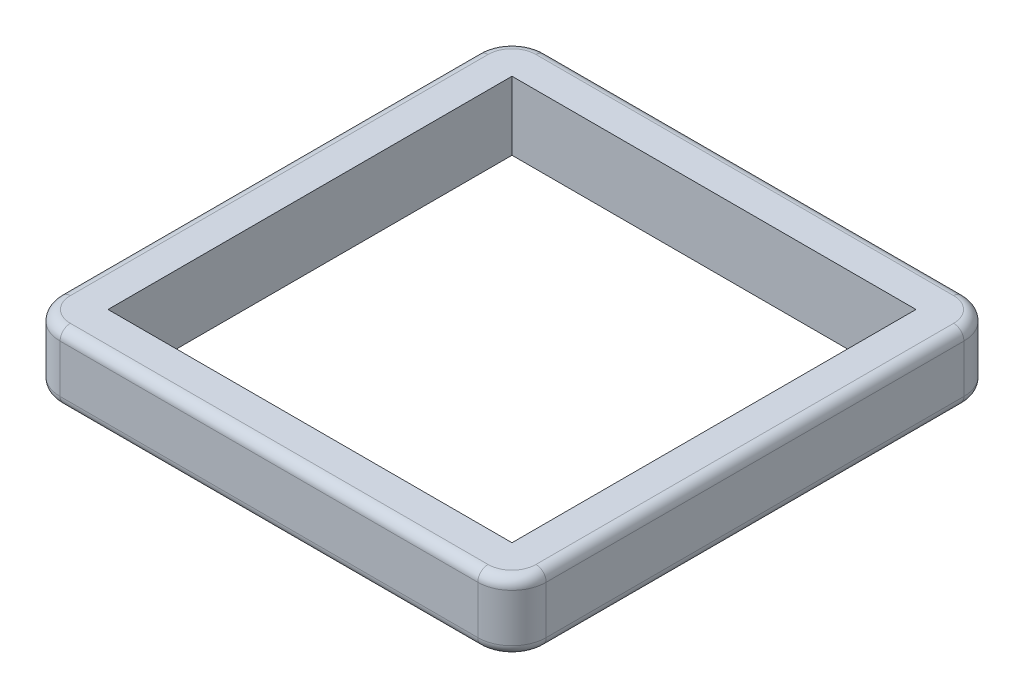
from build123d import *

# Parameters (mm, degrees)
SKETCH1_W           = 901.7
SKETCH1_H           = 901.7
SKETCH1_W_2         = 749.3
SKETCH1_H_2         = 749.3
BOSS_EXTRUDE1_DEPTH = 127
FILLET1_R           = 63.5
FILLET2_R           = 19.05


with BuildPart() as part:
    # Sketch1 → Boss-Extrude1 (new body)
    with BuildSketch(Plane(origin=(0, 0, 0), x_dir=(1, 0, 0), z_dir=(0, 1, 0))):
        Rectangle(SKETCH1_W, SKETCH1_H)
        Rectangle(SKETCH1_W_2, SKETCH1_H_2, mode=Mode.SUBTRACT)
    extrude(amount=BOSS_EXTRUDE1_DEPTH)

    # Fillet1
    fillet1_edges = [part.edges().sort_by_distance(p)[0] for p in [
        (-450.85, 63.5, -450.85),
        (450.85, 63.5, -450.85),
        (450.85, 63.5, 450.85),
        (-450.85, 63.5, 450.85),
    ]]
    fillet(fillet1_edges, radius=FILLET1_R)

    # Fillet2
    fillet2_edges = [part.edges().sort_by_distance(p)[0] for p in [
        (-450.85, 0, 0),
        (-450.85, 127, 0),
        (0, 0, -450.85),
        (450.85, 0, 0),
        (0, 0, 450.85),
        (-432.251280605, 0, 432.251280605),
        (432.251280605, 0, 432.251280605),
        (432.251280605, 0, -432.251280605),
        (-432.251280605, 0, -432.251280605),
        (0, 127, -450.85),
        (0, 127, 450.85),
        (450.85, 127, 0),
        (-432.251280605, 127, 432.251280605),
        (432.251280605, 127, 432.251280605),
        (432.251280605, 127, -432.251280605),
        (-432.251280605, 127, -432.251280605),
    ]]
    fillet(fillet2_edges, radius=FILLET2_R)


solid = part.part
